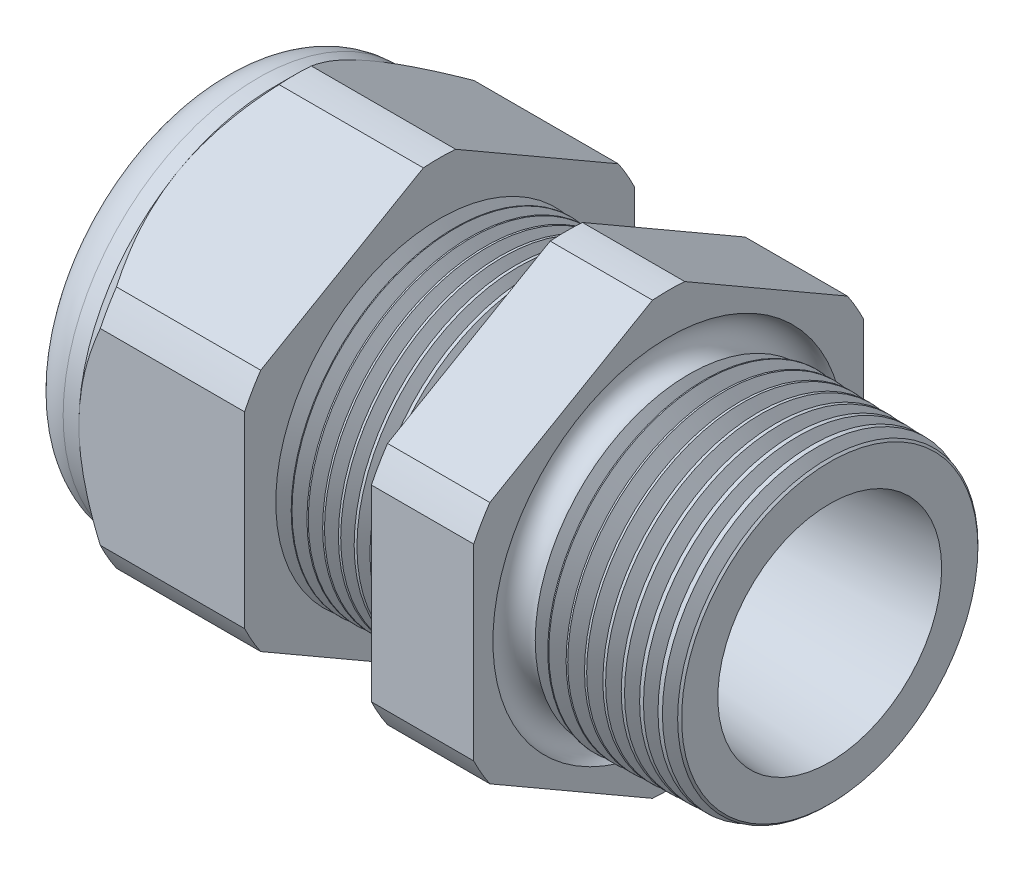
from build123d import *

# Parameters (mm, degrees)
SKETCH12_OUTSIDE_W = 52.432
SKETCH12_OUTSIDE_H = 52.432
CUT_EXTRUDE2_DEPTH = 28.172
FILLET4_R          = 2.032
SKETCH19_OUTSIDE_W = 33.316
SKETCH19_OUTSIDE_H = 35.412
SKETCH19_OUTSIDE_R = 9.525
CUT_EXTRUDE3_DEPTH = 1.999996
CUT_EXTRUDE3_DRAFT = -45
CHAMFER1_SIZE      = 0.260919487
CHAMFER1_SIZE2     = 0.254
SKETCH21_R         = 3.937
PLUG_DEPTH         = 3.81
SKETCH22_R         = 3.683
CUT_EXTRUDE4_DEPTH = 0.508
LPATTERN1_COUNT    = 8
LPATTERN1_PITCH    = 0.762
LPATTERN2_COUNT    = 9
LPATTERN2_PITCH    = 0.889
SKETCH32_R         = 0.889


with BuildPart() as part:
    # Sketch10 → Revolve2 (revolve)
    with BuildSketch(Plane.XY, mode=Mode.PRIVATE) as revolve2_sk:
        Polygon((-29.972, 3.937), (-19.072, 3.937), (0, 5.469582104), (0, 7.501582104), (-7.874, 7.70777005), (-7.874, 19.05), (-12.874, 19.05), (-12.874, 7.838699658), (-19.072, 8.001), (-19.072, 19.05), (-27.172, 19.05), (-27.172, 9.525), (-29.972, 9.525), align=None)
    revolve(revolve2_sk.sketch.rotate(Axis((0, 0, 0), (-1, 0, 0)), 90), axis=Axis((0, 0, 0), (-1, 0, 0)))  # turned: the seam where the file's is

    # Sketch12 outside → Cut-Extrude2 (cut, through all)
    with BuildSketch(Plane.ZY.offset(27.172)):
        Rectangle(SKETCH12_OUTSIDE_W, SKETCH12_OUTSIDE_H)
        with BuildLine():
            Line((-0.788451287, 10.543310065), (-8.736548713, 5.954473877))
            ThreePointArc((-8.736548713, 5.954473877), (-9.156270088, 5.286375), (-9.525, 4.588836188))
            Line((-9.525, 4.588836188), (-9.525, -4.588836188))
            ThreePointArc((-9.525, -4.588836188), (-9.156270088, -5.286375), (-8.736548713, -5.954473877))
            Line((-8.736548713, -5.954473877), (-0.788451287, -10.543310065))
            ThreePointArc((-0.788451287, -10.543310065), (0, -10.57275), (0.788451287, -10.543310065))
            Line((0.788451287, -10.543310065), (8.736548713, -5.954473877))
            ThreePointArc((8.736548713, -5.954473877), (9.156270088, -5.286375), (9.525, -4.588836188))
            Line((9.525, -4.588836188), (9.525, 4.588836188))
            ThreePointArc((9.525, 4.588836188), (9.156270088, 5.286375), (8.736548713, 5.954473877))
            Line((8.736548713, 5.954473877), (0.788451287, 10.543310065))
            ThreePointArc((0.788451287, 10.543310065), (0, 10.57275), (-0.788451287, 10.543310065))
        make_face(mode=Mode.SUBTRACT)
    extrude(amount=-CUT_EXTRUDE2_DEPTH, mode=Mode.SUBTRACT)

    # Fillet4
    fillet4_edges = [part.edges().sort_by_distance(p)[0] for p in [
        (-29.972, 0, 9.525),
    ]]
    fillet(fillet4_edges, radius=FILLET4_R)


with BuildPart() as cut_extrude3_tool:
    # Sketch19 outside → Cut-Extrude3 (with draft: the straight prism first)
    with BuildSketch(Plane.ZY.offset(27.172)):
        Rectangle(SKETCH19_OUTSIDE_W, SKETCH19_OUTSIDE_H)
        Circle(SKETCH19_OUTSIDE_R, mode=Mode.SUBTRACT)
    extrude(amount=-CUT_EXTRUDE3_DEPTH)
    # Cut-Extrude3: the draft: its side faces are tilted about the plane it starts from
    cut_extrude3_sides = [cut_extrude3_tool.faces().sort_by_distance(p)[0] for p in [
        (-26.172002, -17.706, 0),
        (-26.172002, 0, 16.658),
        (-26.172002, 17.706, 0),
        (-26.172002, 0, -16.658),
        (-26.172002, 0, -9.525),
    ]]
    draft(cut_extrude3_sides, Plane.ZY.offset(27.172), CUT_EXTRUDE3_DRAFT)


with BuildPart() as part_1:
    add(part.part)

    # Cut-Extrude3: cut by cut_extrude3_tool
    add(cut_extrude3_tool.part, mode=Mode.SUBTRACT)

    # Chamfer1
    chamfer1_edges = [part_1.edges().sort_by_distance(p)[0] for p in [
        (0, 0, 7.501582104),
    ]]
    chamfer1_side = [part_1.faces().sort_by_distance(p)[0] for p in [
        (0, 0, 5.681758887),
    ]]
    chamfer(chamfer1_edges, length=CHAMFER1_SIZE, length2=CHAMFER1_SIZE2, reference=chamfer1_side[0])

    # Sketch29 → Cut-Revolve1 (revolve, cut)
    with BuildSketch(Plane.XY, mode=Mode.PRIVATE) as cut_revolve1_sk:
        Polygon((-19.072, 8.001), (-18.339016419, 7.981806149), (-18.722130572, 7.356620673), align=None)
    cut_revolve1 = revolve(cut_revolve1_sk.sketch.rotate(Axis((0, 0, 0), (-1, 0, 0)), 90), axis=Axis((0, 0, 0), (-1, 0, 0)), mode=Mode.SUBTRACT)  # turned: the seam where the file's is

    # LPattern1: Cut-Revolve1 ×8
    with Locations(*[(i * LPATTERN1_PITCH, 0, 0) for i in range(1, LPATTERN1_COUNT)]):
        add(cut_revolve1, mode=Mode.SUBTRACT)

    # Sketch30 → Cut-Revolve2 (revolve, cut)
    with BuildSketch(Plane.XY, mode=Mode.PRIVATE) as cut_revolve2_sk:
        Polygon((-7.874, 7.70777005), (-6.994419703, 7.68473743), (-7.454156686, 6.934514858), align=None)
    cut_revolve2 = revolve(cut_revolve2_sk.sketch.rotate(Axis((0, 0, 0), (-1, 0, 0)), 270), axis=Axis((0, 0, 0), (-1, 0, 0)), mode=Mode.SUBTRACT)  # turned: the seam where the file's is

    # LPattern2: Cut-Revolve2 ×9
    with Locations(*[(i * LPATTERN2_PITCH, 0, 0) for i in range(1, LPATTERN2_COUNT)]):
        add(cut_revolve2, mode=Mode.SUBTRACT)

    # Sketch32 → Cut-Revolve3 (revolve, cut)
    with BuildSketch(Plane.XY, mode=Mode.PRIVATE) as cut_revolve3_sk:
        with Locations((-7.747, 7.70777005)):
            Circle(SKETCH32_R)
    revolve(cut_revolve3_sk.sketch.rotate(Axis((0, 0, 0), (-1, 0, 0)), 270), axis=Axis((0, 0, 0), (-1, 0, 0)), mode=Mode.SUBTRACT)  # turned: the seam where the file's is


with BuildPart() as body_2:
    # Sketch21 → plug (new body)
    with BuildSketch(Plane.ZY.offset(29.972)):
        Circle(SKETCH21_R)
    extrude(amount=-PLUG_DEPTH)

    # Sketch22 → Cut-Extrude4 (cut)
    with BuildSketch(Plane.ZY.offset(29.972)):
        Circle(SKETCH22_R)
    extrude(amount=-CUT_EXTRUDE4_DEPTH, mode=Mode.SUBTRACT)


solid = Compound([part_1.part, body_2.part])
